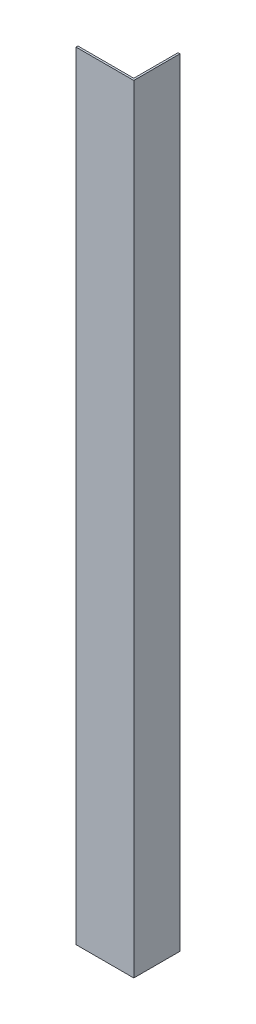
from build123d import *

# Parameters (mm, degrees)
BOSS_EXTRUDE1_DEPTH = 202


with BuildPart() as part:
    # Sketch1 → Boss-Extrude1 (new body)
    with BuildSketch(Plane(origin=(0, 0, 0), x_dir=(1, 0, 0), z_dir=(0, 1, 0))):
        Polygon((0, 0), (15, 0), (15, 12), (14.5, 12), (14.5, 0.5), (0, 0.5), align=None)
    extrude(amount=BOSS_EXTRUDE1_DEPTH)


solid = part.part
